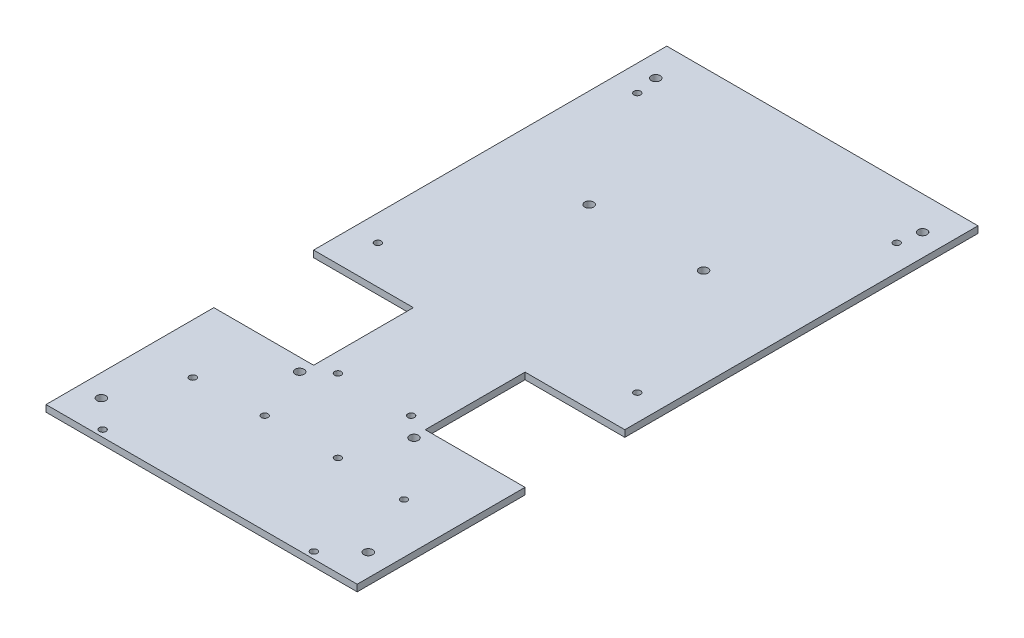
from build123d import *

# Parameters (mm, degrees)
SCHIZZO1_W                   = 140.36
SCHIZZO1_H                   = 280
ESTRUSIONE_ESTRUSIONE1_DEPTH = 3
SCHIZZO2_R                   = 2
TAGLIO_ESTRUSIONE1_DEPTH     = 4
SCHIZZO3_W                   = 45
SCHIZZO3_H                   = 45
TAGLIO_ESTRUSIONE2_DEPTH     = 4
SCHIZZO4_R                   = 1.5
SCHIZZO4_R_2                 = 2
TAGLIO_ESTRUSIONE3_DEPTH     = 4


with BuildPart() as part:
    # Schizzo1 → Estrusione-Estrusione1 (new body)
    with BuildSketch(Plane(origin=(0, 0, 0), x_dir=(1, 0, 0), z_dir=(0, 1, 0))):
        with Locations((-26.670393701, -27.952755906)):
            Rectangle(SCHIZZO1_W, SCHIZZO1_H)
    extrude(amount=ESTRUSIONE_ESTRUSIONE1_DEPTH)

    # Schizzo2 → Taglio-Estrusione1 (cut, through all)
    with BuildSketch(Plane(origin=(0, 3, 0), x_dir=(1, 0, 0), z_dir=(0, 1, 0))):
        with Locations((-86.850393701, -152.952755906)):
            Circle(SCHIZZO2_R)
        with Locations((33.509606299, -152.952755906)):
            Circle(SCHIZZO2_R)
        with Locations((-86.850393701, 97.047244094)):
            Circle(SCHIZZO2_R)
        with Locations((33.509606299, 97.047244094)):
            Circle(SCHIZZO2_R)
    extrude(amount=-TAGLIO_ESTRUSIONE1_DEPTH, mode=Mode.SUBTRACT)

    # Schizzo3 → Taglio-Estrusione2 (cut, through all)
    with BuildSketch(Plane(origin=(0, 0, 0), x_dir=(1, 0, 0), z_dir=(0, 1, 0))):
        with Locations((-74.350393701, -69.752755906)):
            Rectangle(SCHIZZO3_W, SCHIZZO3_H)
        with Locations((21.009606299, -69.752755906)):
            Rectangle(SCHIZZO3_W, SCHIZZO3_H)
    extrude(amount=TAGLIO_ESTRUSIONE2_DEPTH, mode=Mode.SUBTRACT)

    # Schizzo4 → Taglio-Estrusione3 (cut, through all)
    with BuildSketch(Plane(origin=(0, 0, 0), x_dir=(1, 0, 0), z_dir=(0, 1, 0))):
        with Locations((-85.170393701, 87.047244094)):
            Circle(SCHIZZO4_R)
        with Locations((-85.170393701, -29.952755906)):
            Circle(SCHIZZO4_R)
        with Locations((31.829606299, -29.952755906)):
            Circle(SCHIZZO4_R)
        with Locations((31.829606299, 87.047244094)):
            Circle(SCHIZZO4_R)
        with Locations((-43.180393701, -89.952755906)):
            Circle(SCHIZZO4_R)
        with Locations((-10.160393701, -89.952755906)):
            Circle(SCHIZZO4_R)
        with Locations((-10.160393701, -122.972755906)):
            Circle(SCHIZZO4_R)
        with Locations((-43.180393701, -122.972755906)):
            Circle(SCHIZZO4_R)
        with Locations((-52.470393701, -97.952755906)):
            Circle(SCHIZZO4_R_2)
        with Locations((-0.870393701, -97.952755906)):
            Circle(SCHIZZO4_R_2)
        with Locations((-0.870393701, 32.647244094)):
            Circle(SCHIZZO4_R_2)
        with Locations((-52.470393701, 32.647244094)):
            Circle(SCHIZZO4_R_2)
        with Locations((-74.295393701, -124.312755906)):
            Circle(SCHIZZO4_R)
        with Locations((20.954606299, -124.312755906)):
            Circle(SCHIZZO4_R)
        with Locations((20.954606299, -164.952755906)):
            Circle(SCHIZZO4_R)
        with Locations((-74.295393701, -164.952755906)):
            Circle(SCHIZZO4_R)
    extrude(amount=TAGLIO_ESTRUSIONE3_DEPTH, mode=Mode.SUBTRACT)


solid = part.part
